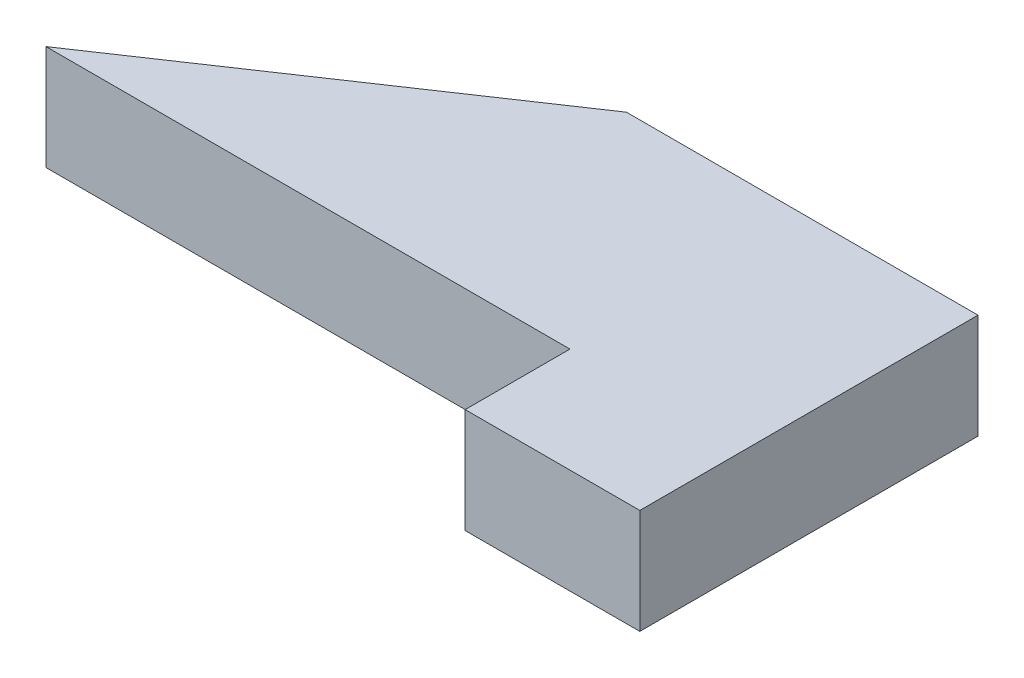
from build123d import *

# Parameters (mm, degrees)
BOSS_EXTRUDE1_DEPTH = 3


with BuildPart() as part:
    # Sketch1 → Boss-Extrude1 (new body)
    with BuildSketch(Plane(origin=(0, 0, 0), x_dir=(1, 0, 0), z_dir=(0, 1, 0))):
        Polygon((-20, 3), (-10.065787968, 9.682098142), (0, 9.682098142), (0, 3), (0, 0), (-5, 0), (-5, 3), align=None)
    extrude(amount=BOSS_EXTRUDE1_DEPTH)


solid = part.part
